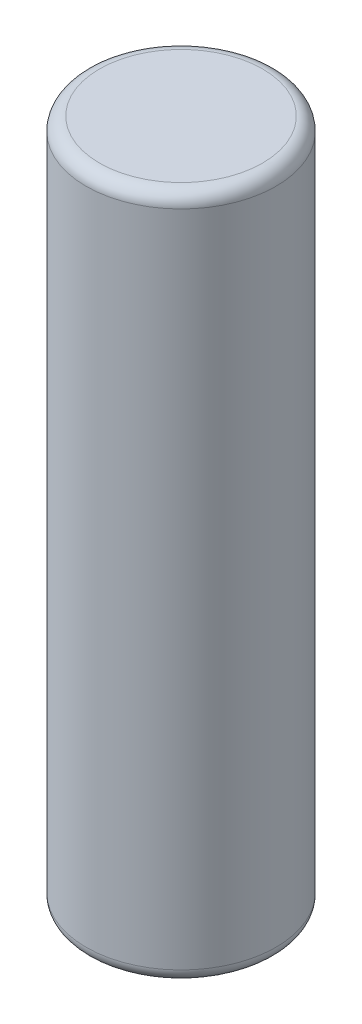
from build123d import *

# Parameters (mm, degrees)
SKETCH1_R           = 9
BOSS_EXTRUDE1_DEPTH = 65
FILLET1_R           = 1.27


with BuildPart() as part:
    # Sketch1 → Boss-Extrude1 (new body)
    with BuildSketch(Plane(origin=(0, 0, 0), x_dir=(1, 0, 0), z_dir=(0, 1, 0))):
        Circle(SKETCH1_R)
    extrude(amount=BOSS_EXTRUDE1_DEPTH)

    # Fillet1
    fillet1_edges = [part.edges().sort_by_distance(p)[0] for p in [
        (-9, 0, 0),
        (-9, 65, 0),
    ]]
    fillet(fillet1_edges, radius=FILLET1_R)


solid = part.part
